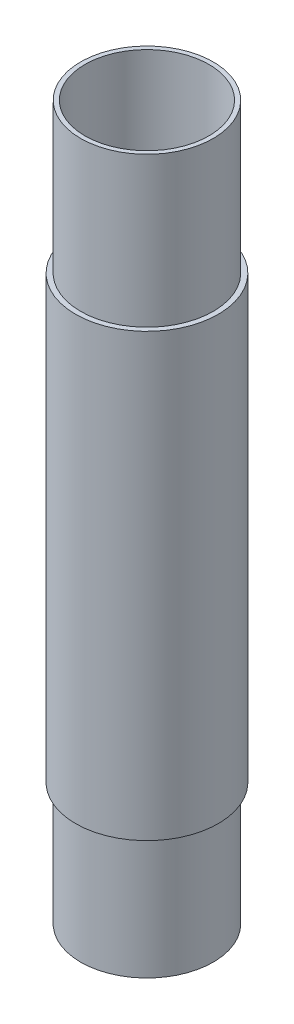
from build123d import *

# Parameters (mm, degrees)
DRIVER_R            = 27.06751
DRIVER_R_2          = 25.29025
BOSS_EXTRUDE1_DEPTH = 80
BOSS_EXTRUDE2_START = 50
DRIVER_3_R          = 29.1211
DRIVER_3_R_2        = 27.06751
BOSS_EXTRUDE2_DEPTH = 180
BOSS_EXTRUDE3_START = 200
DRIVER_4_R          = 27.06751
DRIVER_4_R_2        = 25.29025
BOSS_EXTRUDE3_DEPTH = 91.12


with BuildPart() as part:
    # driver → Boss-Extrude1 (new body)
    with BuildSketch(Plane(origin=(0, 0, 0), x_dir=(1, 0, 0), z_dir=(0, 1, 0))):
        Circle(DRIVER_R)
        Circle(DRIVER_R_2, mode=Mode.SUBTRACT)
    extrude(amount=BOSS_EXTRUDE1_DEPTH)

    # driver_3 → Boss-Extrude2 (add)
    with BuildSketch(Plane(origin=(0, 0, 0), x_dir=(1, 0, 0), z_dir=(0, 1, 0)).offset(BOSS_EXTRUDE2_START)):
        Circle(DRIVER_3_R)
        Circle(DRIVER_3_R_2, mode=Mode.SUBTRACT)
    extrude(amount=BOSS_EXTRUDE2_DEPTH)

    # driver_4 → Boss-Extrude3 (add)
    with BuildSketch(Plane(origin=(0, 0, 0), x_dir=(1, 0, 0), z_dir=(0, 1, 0)).offset(BOSS_EXTRUDE3_START)):
        Circle(DRIVER_4_R)
        Circle(DRIVER_4_R_2, mode=Mode.SUBTRACT)
    extrude(amount=BOSS_EXTRUDE3_DEPTH)


solid = part.part
